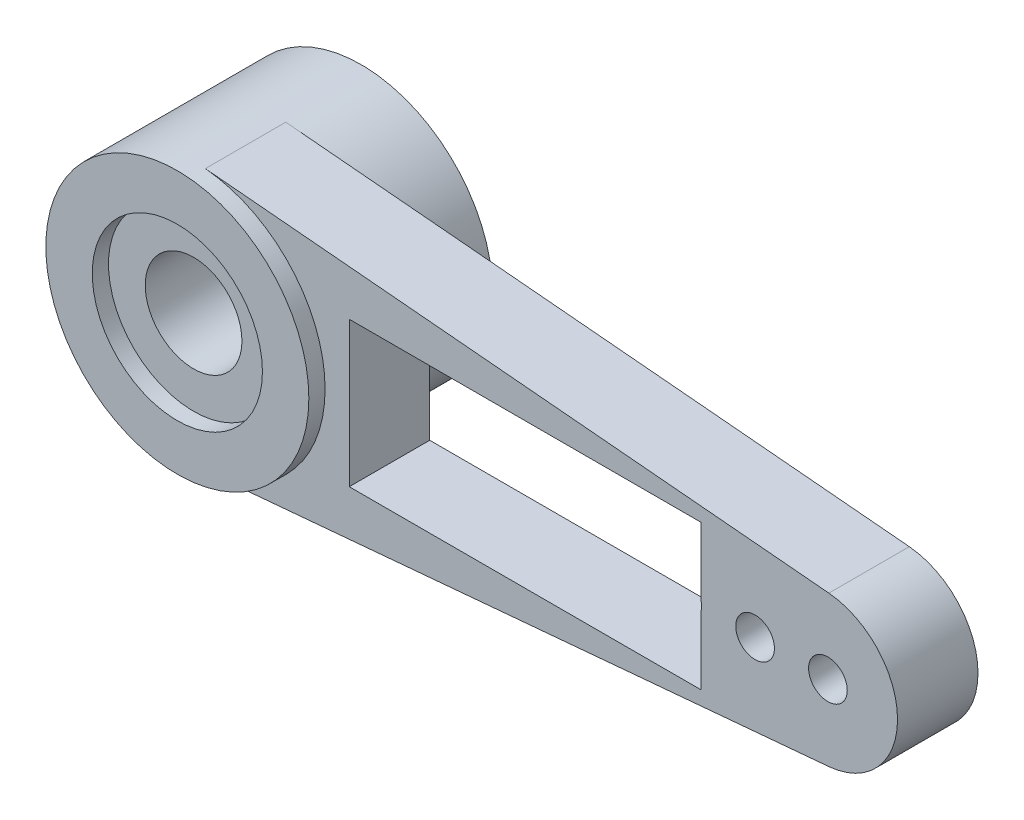
from build123d import *
from build123d.topology import SkipClean

# Parameters (mm, degrees)
SKETCH1_R               = 0.5
SKETCH1_R_2             = 1.25
BASE_DEPTH              = 2.08
CONNECTION_DEPTH        = 2.5
CONNECTION_DEPTH_BACK   = 2.25
SKETCH1_3_R             = 2.2
SKETCH2_W               = 9.1
SKETCH2_H               = 3.75
ALIGNMENT_CHANNEL_DEPTH = 10


with BuildPart() as part:
    # Sketch1 → Base (new body)
    with BuildSketch(Plane.XY):
        with BuildLine():
            ThreePointArc((16.424, -1.942221409), (18.2, 0), (16.424, 1.942221409))
            Line((16.424, 1.942221409), (0.303384615, 3.386437328))
            ThreePointArc((0.303384615, 3.386437328), (-3.4, 0), (0.303384615, -3.386437328))
            Line((0.303384615, -3.386437328), (16.424, -1.942221409))
        make_face()
        with Locations((5.1, 0)):
            Circle(SKETCH1_R, mode=Mode.SUBTRACT)
        with Locations((6.983333333, 0)):
            Circle(SKETCH1_R, mode=Mode.SUBTRACT)
        with Locations((8.866666667, 0)):
            Circle(SKETCH1_R, mode=Mode.SUBTRACT)
        with Locations((10.75, 0)):
            Circle(SKETCH1_R, mode=Mode.SUBTRACT)
        with Locations((12.633333333, 0)):
            Circle(SKETCH1_R, mode=Mode.SUBTRACT)
        with Locations((14.516666667, 0)):
            Circle(SKETCH1_R, mode=Mode.SUBTRACT)
        with Locations((16.4, 0)):
            Circle(SKETCH1_R, mode=Mode.SUBTRACT)
        Circle(SKETCH1_R_2, mode=Mode.SUBTRACT)
    extrude(amount=BASE_DEPTH)

    # Sketch1_3 → Connection (add, two sides: drawn at the far end of the back side and taken through both)
    with SkipClean():  # the faces are left unmerged after this step: merging them gives an invalid solid
        with BuildSketch(Plane.XY.offset(-CONNECTION_DEPTH_BACK)):
            with BuildLine():
                ThreePointArc((3.4, 0), (2.509134083, 2.294394507), (0.303384615, 3.386437328))
                ThreePointArc((0.303384615, 3.386437328), (-3.4, 0), (0.303384615, -3.386437328))
                ThreePointArc((0.303384615, -3.386437328), (2.509134083, -2.294394507), (3.4, 0))
            make_face()
            Circle(SKETCH1_3_R, mode=Mode.SUBTRACT)
        extrude(amount=CONNECTION_DEPTH + CONNECTION_DEPTH_BACK)

    # Sketch2 → Alignment channel (cut)
    with SkipClean():  # the faces are left unmerged after this step: merging them gives an invalid solid
        with BuildSketch(Plane(origin=(0, 0, 0), x_dir=(-1, 0, 0), z_dir=(0, 0, -1))):
            with Locations((-8.575, 0)):
                Rectangle(SKETCH2_W, SKETCH2_H)
        extrude(amount=-ALIGNMENT_CHANNEL_DEPTH, mode=Mode.SUBTRACT)


solid = part.part
